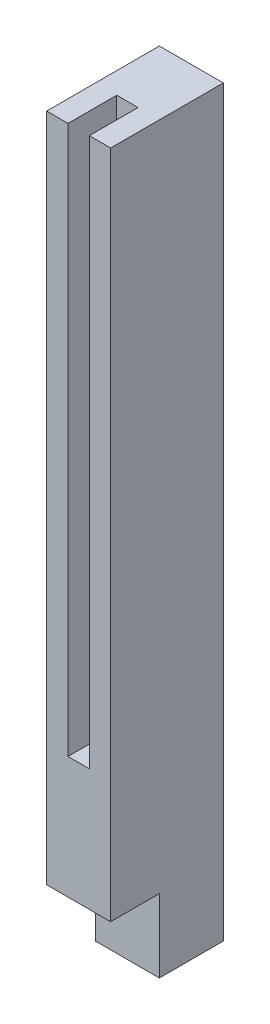
from build123d import *

# Parameters (mm, degrees)
SKETCH1_W           = 5.25
SKETCH1_H           = 5.25
BOSS_EXTRUDE1_DEPTH = 6
SKETCH2_W           = 5.25
SKETCH2_H           = 9.25
BOSS_EXTRUDE2_DEPTH = 55
SKETCH3_W           = 1.75
SKETCH3_H           = 8
CUT_EXTRUDE1_DEPTH  = 45


with BuildPart() as part:
    # Sketch1 → Boss-Extrude1 (new body)
    with BuildSketch(Plane(origin=(0, 0, 0), x_dir=(1, 0, 0), z_dir=(0, 1, 0))):
        Rectangle(SKETCH1_W, SKETCH1_H)
    extrude(amount=BOSS_EXTRUDE1_DEPTH)

    # Sketch2 → Boss-Extrude2 (add)
    with BuildSketch(Plane(origin=(0, 6, 0), x_dir=(1, 0, 0), z_dir=(0, 1, 0))):
        with Locations((0, -2)):
            Rectangle(SKETCH2_W, SKETCH2_H)
    extrude(amount=BOSS_EXTRUDE2_DEPTH)

    # Sketch3 → Cut-Extrude1 (cut)
    with BuildSketch(Plane(origin=(0, 61, 0), x_dir=(1, 0, 0), z_dir=(0, 1, 0))):
        with Locations((0, -6.625)):
            Rectangle(SKETCH3_W, SKETCH3_H)
    extrude(amount=-CUT_EXTRUDE1_DEPTH, mode=Mode.SUBTRACT)


solid = part.part
